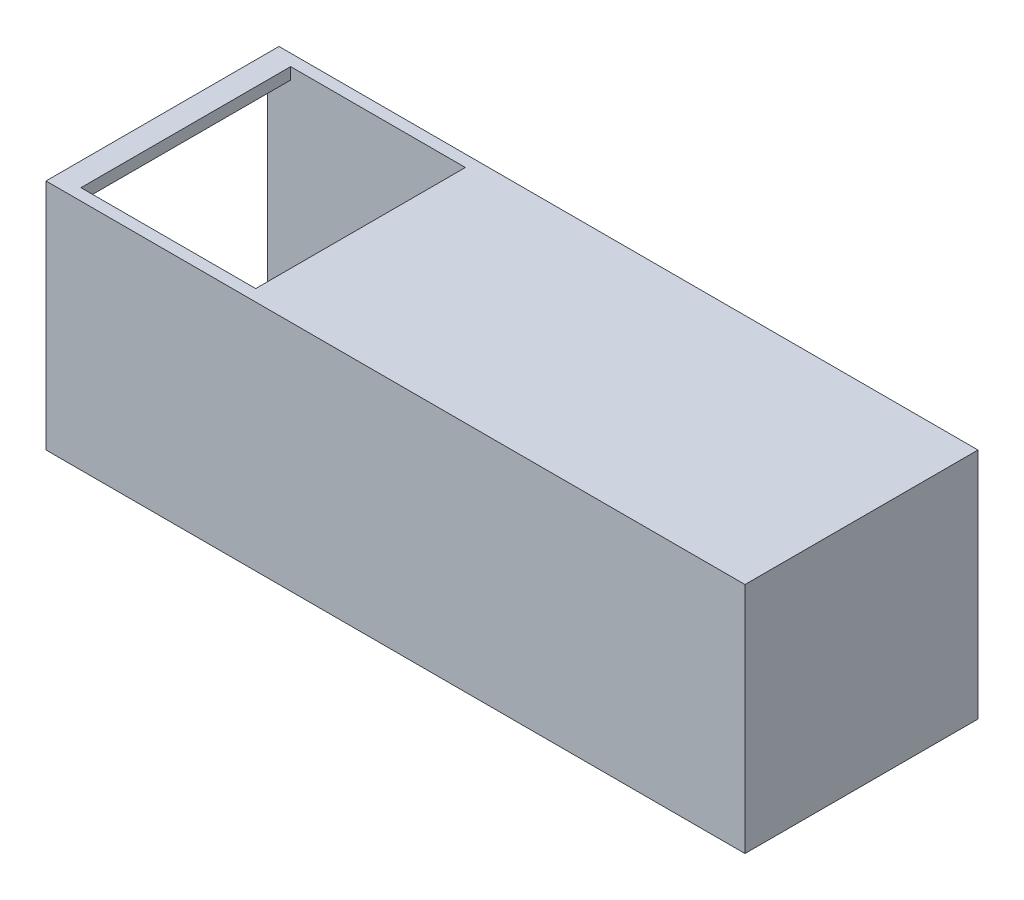
from build123d import *

# Parameters (mm, degrees)
SKETCH1_W           = 120
SKETCH1_H           = 40
BOSS_EXTRUDE1_DEPTH = 40
SHELL1_T            = -2
SKETCH2_R           = 18
CUT_EXTRUDE1_DEPTH  = 3
CUT_EXTRUDE2_REACH  = 42
SKETCH3_W           = 30
SKETCH3_H           = 36


with BuildPart() as part:
    # Sketch1 → Boss-Extrude1 (new body)
    with BuildSketch(Plane(origin=(0, 0, 0), x_dir=(1, 0, 0), z_dir=(0, 1, 0))):
        with Locations((-60, 20)):
            Rectangle(SKETCH1_W, SKETCH1_H)
    extrude(amount=BOSS_EXTRUDE1_DEPTH)

    # Shell1
    shell1_openings = [part.faces().sort_by_distance(p)[0] for p in [
        (-120, 20, -20),
    ]]
    offset(amount=SHELL1_T, openings=shell1_openings, kind=Kind.INTERSECTION)

    # Sketch2 → Cut-Extrude1 (cut, through all)
    with BuildSketch(Plane(origin=(0, 2, 0), x_dir=(1, 0, 0), z_dir=(0, 1, 0))):
        with Locations((-20, 20)):
            Circle(SKETCH2_R)
    extrude(amount=-CUT_EXTRUDE1_DEPTH, mode=Mode.SUBTRACT)

    # Sketch3 → Cut-Extrude2 (cut, up to next)
    with BuildSketch(Plane(origin=(0, 40, 0), x_dir=(1, 0, 0), z_dir=(0, 1, 0)), mode=Mode.PRIVATE) as cut_extrude2_sk1:
        with Locations((-101, 20)):
            Rectangle(SKETCH3_W, SKETCH3_H)
    cut_extrude2_tool1 = extrude(cut_extrude2_sk1.sketch, amount=-CUT_EXTRUDE2_REACH, mode=Mode.PRIVATE) & part.part
    add(cut_extrude2_tool1.solids().sort_by_distance((-101, 40, -20))[0], mode=Mode.SUBTRACT)


solid = part.part
